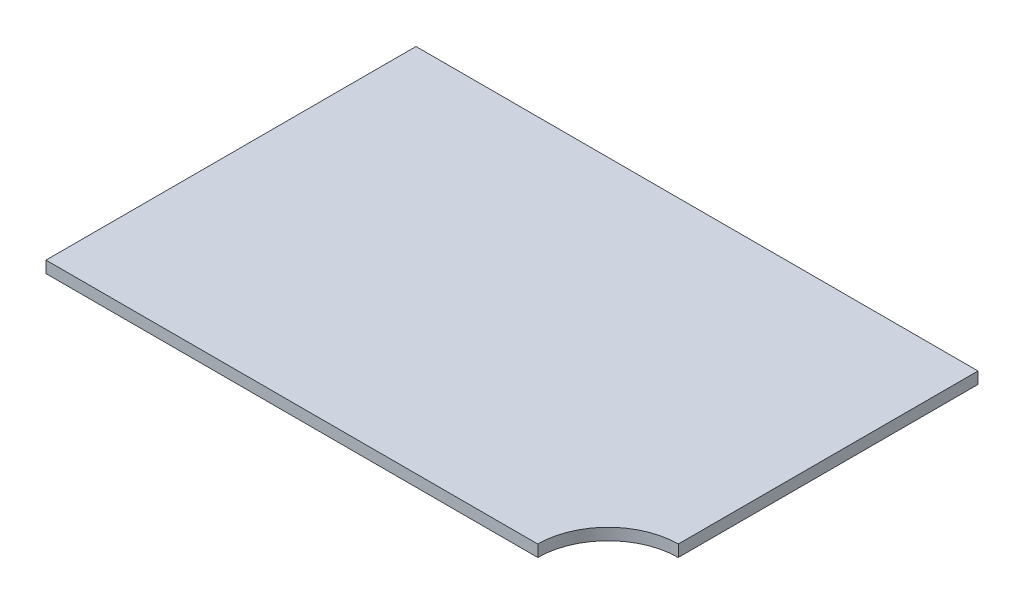
from build123d import *

# Parameters (mm, degrees)
SKETCH1_W           = 240
SKETCH1_H           = 158
BOSS_EXTRUDE1_DEPTH = 5
CUT_EXTRUDE1_DEPTH  = 6


with BuildPart() as part:
    # Sketch1 → Boss-Extrude1 (new body)
    with BuildSketch(Plane(origin=(0, 0, 0), x_dir=(1, 0, 0), z_dir=(0, 1, 0))):
        with Locations((0, -79)):
            Rectangle(SKETCH1_W, SKETCH1_H)
    extrude(amount=BOSS_EXTRUDE1_DEPTH)

    # Sketch5 → Cut-Extrude1 (cut, through all)
    with BuildSketch(Plane.XZ):
        with BuildLine():
            Line((120, 158), (120, 128))
            ThreePointArc((120, 128), (98.786796564, 136.786796564), (90, 158))
            Line((90, 158), (120, 158))
        make_face()
    extrude(amount=-CUT_EXTRUDE1_DEPTH, mode=Mode.SUBTRACT)


solid = part.part
